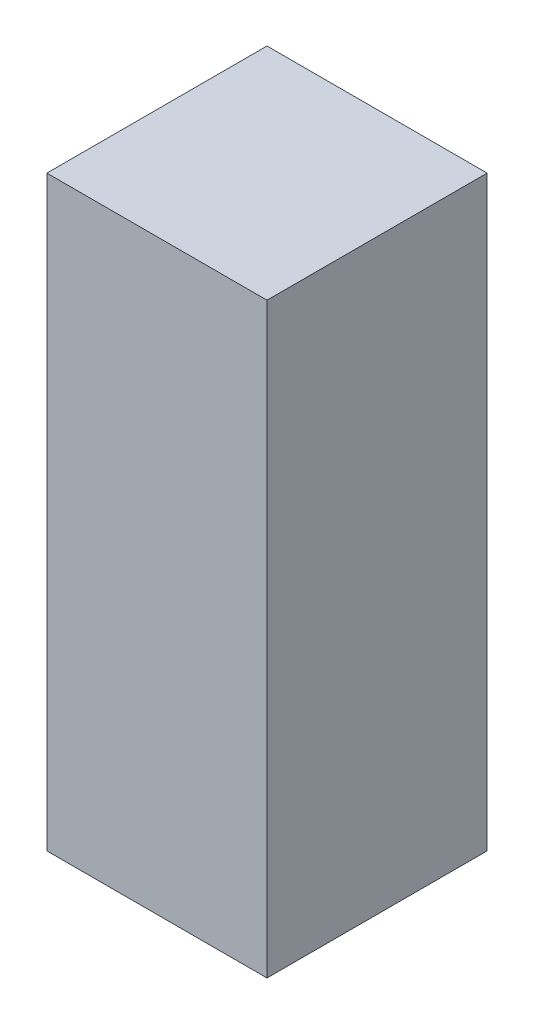
from build123d import *

# Parameters (mm, degrees)
SKETCH1_W           = 3
SKETCH1_H           = 3
BOSS_EXTRUDE1_DEPTH = 8


with BuildPart() as part:
    # Sketch1 → Boss-Extrude1 (new body)
    with BuildSketch(Plane(origin=(0, 0, 0), x_dir=(1, 0, 0), z_dir=(0, 1, 0))):
        with Locations((1.5, 1.5)):
            Rectangle(SKETCH1_W, SKETCH1_H)
    extrude(amount=BOSS_EXTRUDE1_DEPTH)


solid = part.part
